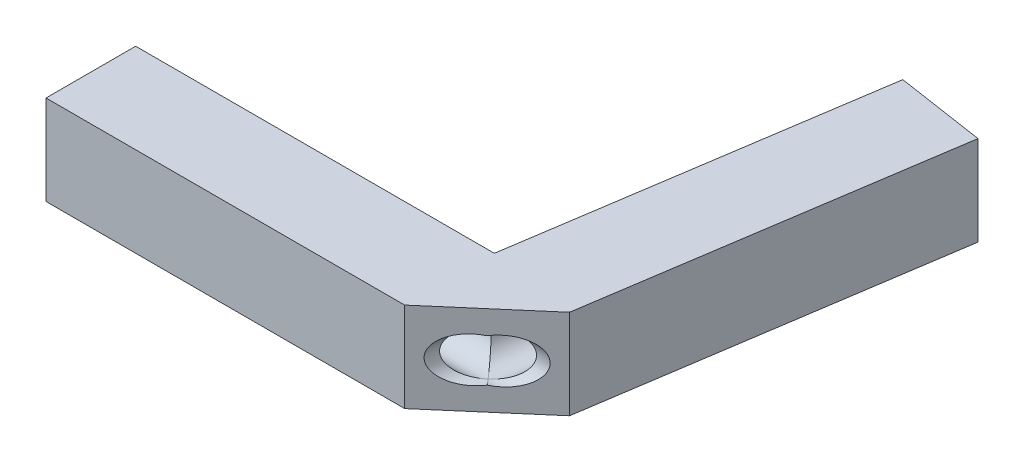
from build123d import *

# Parameters (mm, degrees)
BOSS_EXTRUDE1_DEPTH = 2
SKETCH3_R           = 0.5
CUT_EXTRUDE1_DEPTH  = 12
SKETCH4_R           = 0.5
CUT_EXTRUDE3_DEPTH  = 12


with BuildPart() as part:
    # Sketch2 → Boss-Extrude1 (new body)
    with BuildSketch(Plane(origin=(0, 0, 0), x_dir=(1, 0, 0), z_dir=(0, 1, 0))):
        Polygon((-8, -2), (0, -2), (1.977355898, -0.300106069), (3.177780174, 7.609317523), (1.200424276, 7.909423592), (0, 0), (-8, 0), align=None)
    extrude(amount=BOSS_EXTRUDE1_DEPTH)

    # Sketch3 → Cut-Extrude1 (cut)
    with BuildSketch(Plane.ZY.offset(8)):
        with Locations((1, 1)):
            Circle(SKETCH3_R)
    extrude(amount=-CUT_EXTRUDE1_DEPTH, mode=Mode.SUBTRACT)

    # Sketch4 → Cut-Extrude3 (cut)
    with BuildSketch(Plane(origin=(1.200424276, 0, -7.909423592), x_dir=(-0.9886779489912622, 0, -0.15005303455255817), z_dir=(0.15005303455255817, 0, -0.9886779489912622))):
        with Locations((-1, 1)):
            Circle(SKETCH4_R)
    extrude(amount=-CUT_EXTRUDE3_DEPTH, mode=Mode.SUBTRACT)


solid = part.part
